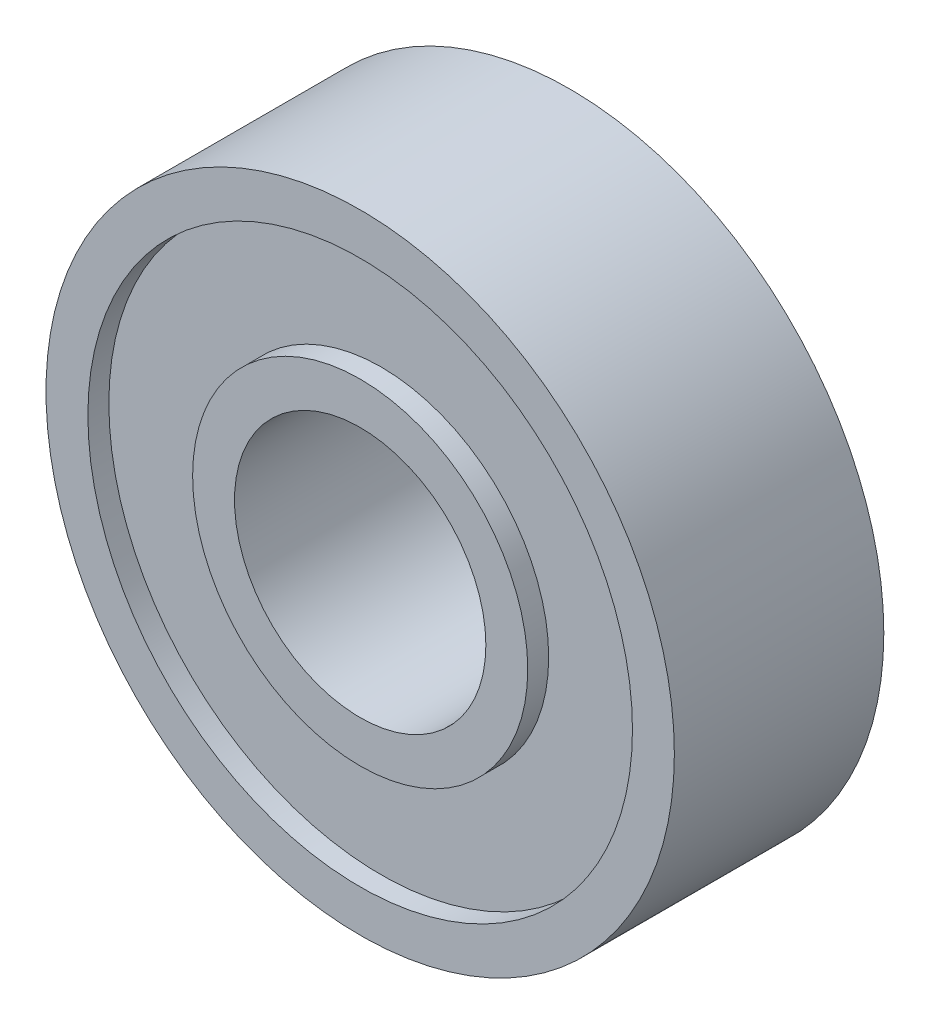
from build123d import *

# Parameters (mm, degrees)
ESQUISSE1_R             = 7.5
ESQUISSE1_R_2           = 3
BOSS_EXTRU_1_DEPTH      = 5
ESQUISSE2_R             = 6.5
ESQUISSE2_R_2           = 4
ENL_V_MAT_EXTRU_1_DEPTH = 0.5


with BuildPart() as part:
    # Esquisse1 → Boss.-Extru.1 (new body)
    with BuildSketch(Plane.XY):
        Circle(ESQUISSE1_R)
        Circle(ESQUISSE1_R_2, mode=Mode.SUBTRACT)
    extrude(amount=BOSS_EXTRU_1_DEPTH)

    # Esquisse2 → Enlèv. mat.-Extru.1 (cut)
    with BuildSketch(Plane.XY.offset(5)):
        Circle(ESQUISSE2_R)
        Circle(ESQUISSE2_R_2, mode=Mode.SUBTRACT)
    enl_v_mat_extru_1 = extrude(amount=-ENL_V_MAT_EXTRU_1_DEPTH, mode=Mode.SUBTRACT)

    # Symétrie2: Enlèv. mat.-Extru.1 across plane
    add(enl_v_mat_extru_1.mirror(Plane(origin=(0, 0, 2.5), x_dir=(1, 0, 0), z_dir=(0, 0, -1))), mode=Mode.SUBTRACT)


solid = part.part
